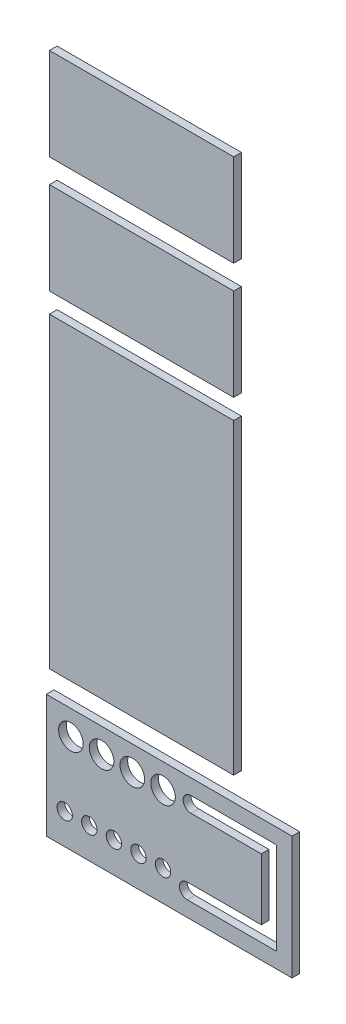
from build123d import *

# Parameters (mm, degrees)
SKETCH4_W             = 101.6
SKETCH4_H             = 50.8
SKETCH4_R             = 3.175
SKETCH4_R_2           = 5.08
BOSS_EXTRUDE1_DEPTH   = 3.175
SKETCH4_W_2           = 76.2
SKETCH4_H_2           = 127
BOSS_EXTRUDE1_2_DEPTH = 3.175
SKETCH4_H_3           = 38.1
BOSS_EXTRUDE1_3_DEPTH = 3.175
BOSS_EXTRUDE1_4_DEPTH = 3.175


with BuildPart() as part:
    # Sketch4 → Boss-Extrude1 (new body)
    with BuildSketch(Plane.XY):
        with Locations((57.035846179, 29.225487274)):
            Rectangle(SKETCH4_W, SKETCH4_H)
        with Locations((13.855846179, 16.525487274)):
            Circle(SKETCH4_R, mode=Mode.SUBTRACT)
        with Locations((24.015846179, 16.525487274)):
            Circle(SKETCH4_R, mode=Mode.SUBTRACT)
        with Locations((34.175846179, 16.525487274)):
            Circle(SKETCH4_R, mode=Mode.SUBTRACT)
        with Locations((44.335846179, 16.525487274)):
            Circle(SKETCH4_R, mode=Mode.SUBTRACT)
        with Locations((54.495846179, 16.525487274)):
            Circle(SKETCH4_R, mode=Mode.SUBTRACT)
        with Locations((16.395846179, 44.465487274)):
            Circle(SKETCH4_R_2, mode=Mode.SUBTRACT)
        with Locations((29.095846179, 44.465487274)):
            Circle(SKETCH4_R_2, mode=Mode.SUBTRACT)
        with Locations((41.795846179, 44.465487274)):
            Circle(SKETCH4_R_2, mode=Mode.SUBTRACT)
        with Locations((54.495846179, 44.465487274)):
            Circle(SKETCH4_R_2, mode=Mode.SUBTRACT)
        with BuildLine():
            Line((64.46655377, 16.525487274), (95.135846179, 16.525487274))
            Line((95.135846179, 16.525487274), (95.135846179, 41.925487274))
            Line((95.135846179, 41.925487274), (66.004814465, 41.925487274))
            ThreePointArc((66.004814465, 41.925487274), (62.829814465, 45.100487274), (66.004814465, 48.275487274))
            Line((66.004814465, 48.275487274), (101.485846179, 48.275487274))
            Line((101.485846179, 48.275487274), (101.485846179, 10.175487274))
            Line((101.485846179, 10.175487274), (64.46655377, 10.175487274))
            ThreePointArc((64.46655377, 10.175487274), (61.29155377, 13.350487274), (64.46655377, 16.525487274))
        make_face(mode=Mode.SUBTRACT)
    extrude(amount=BOSS_EXTRUDE1_DEPTH)


with BuildPart() as body_2:
    # Sketch4 → Boss-Extrude1 2 (new body)
    with BuildSketch(Plane.XY):
        with Locations((45.624983243, 127.887090926)):
            Rectangle(SKETCH4_W_2, SKETCH4_H_2)
    extrude(amount=BOSS_EXTRUDE1_2_DEPTH)


with BuildPart() as body_3:
    # Sketch4 → Boss-Extrude1 3 (new body)
    with BuildSketch(Plane.XY):
        with Locations((45.624983243, 266.747740762)):
            Rectangle(SKETCH4_W_2, SKETCH4_H_3)
    extrude(amount=BOSS_EXTRUDE1_3_DEPTH)


with BuildPart() as body_4:
    # Sketch4 → Boss-Extrude1 4 (new body)
    with BuildSketch(Plane.XY):
        with Locations((45.624983243, 218.702437589)):
            Rectangle(SKETCH4_W_2, SKETCH4_H_3)
    extrude(amount=BOSS_EXTRUDE1_4_DEPTH)


solid = Compound([part.part, body_2.part, body_3.part, body_4.part])
